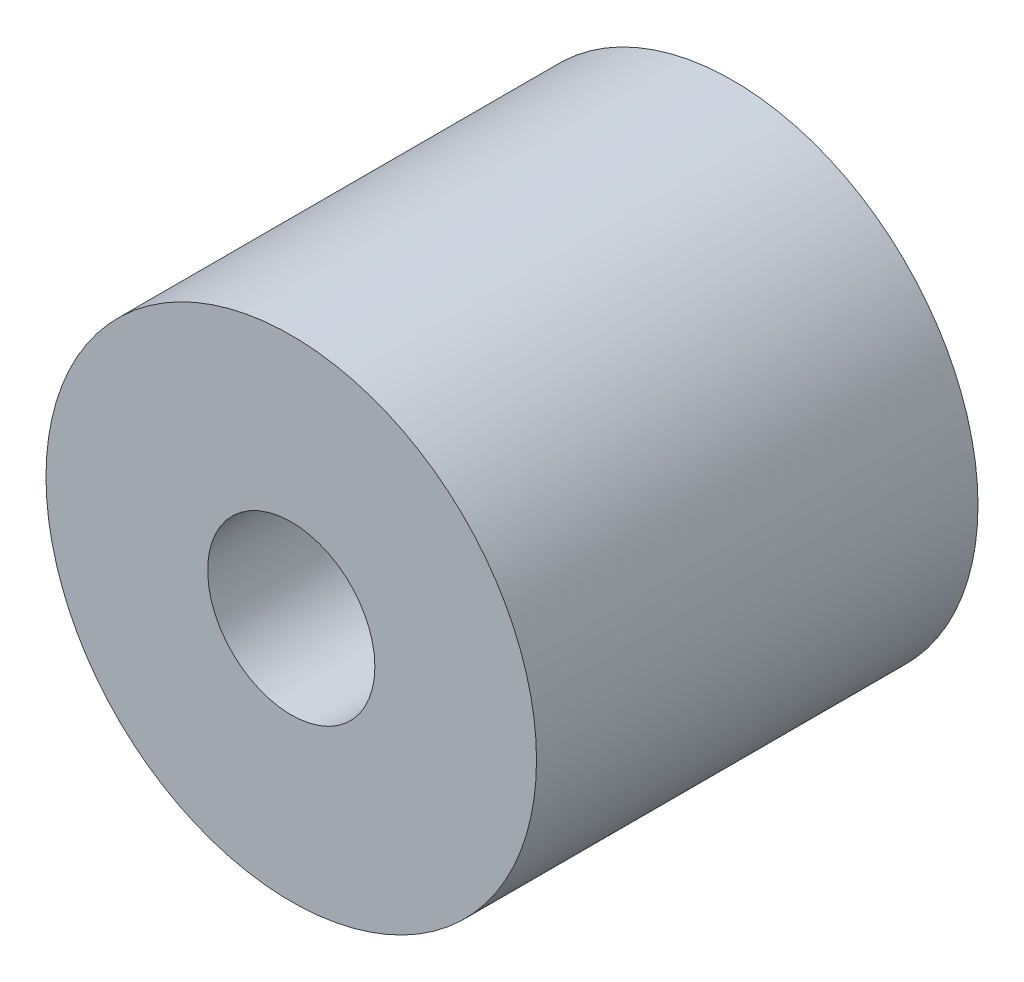
from build123d import *

# Parameters (mm, degrees)
ESBO_O1_R                = 5.5
ESBO_O1_R_2              = 1.875
RESSALTO_EXTRUS_O1_DEPTH = 9.9


with BuildPart() as part:
    # Esboço1 → Ressalto-extrusão1 (new body)
    with BuildSketch(Plane.XY):
        Circle(ESBO_O1_R)
        Circle(ESBO_O1_R_2, mode=Mode.SUBTRACT)
    extrude(amount=RESSALTO_EXTRUS_O1_DEPTH)


solid = part.part
